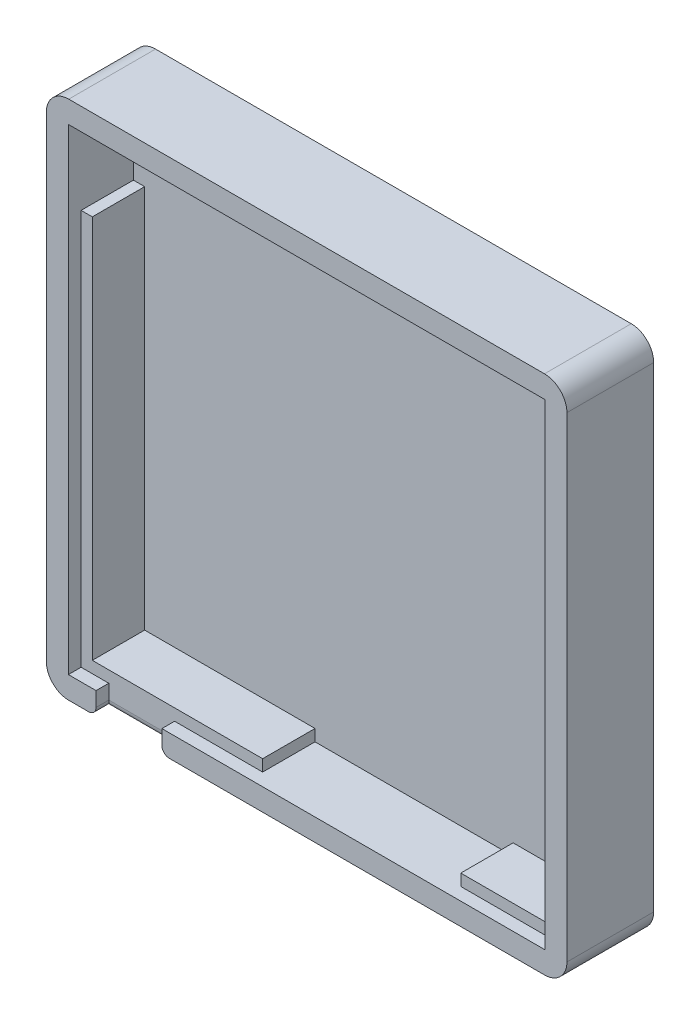
from build123d import *

# Parameters (mm, degrees)
SKETCH1_W           = 69.6
SKETCH1_H           = 69.6
BOSS_EXTRUDE1_DEPTH = 11.6
SKETCH2_W           = 60.7
SKETCH2_H           = 60.6
CUT_EXTRUDE3_DEPTH  = 8.7
SKETCH4_W           = 63.7
SKETCH4_H           = 63.7
CUT_EXTRUDE4_DEPTH  = 1.7
SKETCH5_W           = 8.8
SKETCH5_H           = 2.95
CUT_EXTRUDE5_DEPTH  = 1.7
SKETCH6_W           = 10.090148406
SKETCH6_H           = 10.8025245
SKETCH6_W_2         = 26.487438399
SKETCH6_H_2         = 3.614002098
SKETCH6_W_3         = 9.895864017
CUT_EXTRUDE6_DEPTH  = 7
FILLET1_R           = 3
FILLET2_R           = 1


with BuildPart() as part:
    # Sketch1 → Boss-Extrude1 (new body)
    with BuildSketch(Plane.XY):
        with Locations((34.8, 34.8)):
            Rectangle(SKETCH1_W, SKETCH1_H)
    extrude(amount=BOSS_EXTRUDE1_DEPTH)

    # Sketch2 → Cut-Extrude3 (cut)
    with BuildSketch(Plane.XY.offset(11.6)):
        with Locations((34.8, 34.8)):
            Rectangle(SKETCH2_W, SKETCH2_H)
    extrude(amount=-CUT_EXTRUDE3_DEPTH, mode=Mode.SUBTRACT)

    # Sketch4 → Cut-Extrude4 (cut)
    with BuildSketch(Plane.XY.offset(11.6)):
        with Locations((34.8, 34.8)):
            Rectangle(SKETCH4_W, SKETCH4_H)
    extrude(amount=-CUT_EXTRUDE4_DEPTH, mode=Mode.SUBTRACT)

    # Sketch5 → Cut-Extrude5 (cut)
    with BuildSketch(Plane.XY.offset(11.6)):
        with Locations((11.05, 1.475)):
            Rectangle(SKETCH5_W, SKETCH5_H)
    extrude(amount=-CUT_EXTRUDE5_DEPTH, mode=Mode.SUBTRACT)

    # Sketch6 → Cut-Extrude6 (cut)
    with BuildSketch(Plane.XY.offset(9.9)):
        with Locations((7.995074203, 61.24873775)):
            Rectangle(SKETCH6_W, SKETCH6_H)
        with Locations((40.46662802, 4.757001049)):
            Rectangle(SKETCH6_W_2, SKETCH6_H_2)
        with Locations((61.702067992, 61.24873775)):
            Rectangle(SKETCH6_W_3, SKETCH6_H)
    extrude(amount=-CUT_EXTRUDE6_DEPTH, mode=Mode.SUBTRACT)

    # Fillet1
    fillet1_edges = [part.edges().sort_by_distance(p)[0] for p in [
        (0, 69.6, 5.8),
        (69.6, 69.6, 5.8),
        (69.6, 0, 5.8),
        (0, 0, 5.8),
    ]]
    fillet(fillet1_edges, radius=FILLET1_R)

    # Fillet2
    fillet2_edges = [part.edges().sort_by_distance(p)[0] for p in [
        (11.05, 0, 9.9),
        (15.45, 0, 10.75),
        (6.65, 0, 10.75),
    ]]
    fillet(fillet2_edges, radius=FILLET2_R)


solid = part.part
